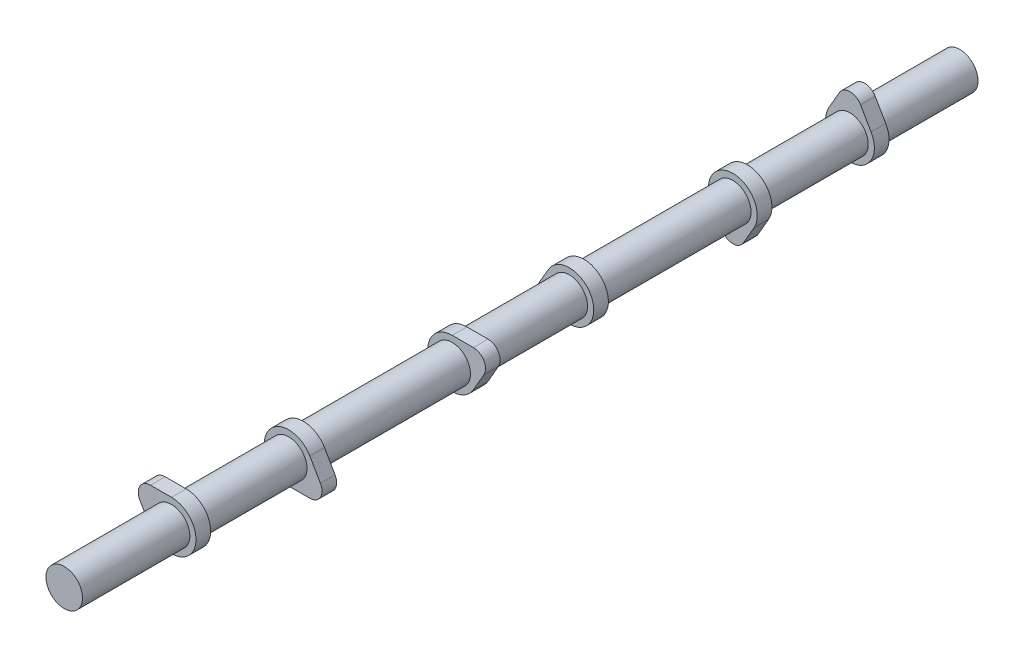
from build123d import *

# Parameters (mm, degrees)
BOSS_EXTRU_1_DEPTH           = 3.81
CORPS_D_PLACER_COPIER2_ANGLE = 180
BOSS_EXTRU_2_START           = -25.4
ESQUISSE4_R                  = 9.5
BOSS_EXTRU_2_DEPTH           = 146.05
R_P_TITION_LIN_AIRE2_COUNT   = 3
R_P_TITION_LIN_AIRE2_PITCH   = 146.05
CORPS_D_PLACER_COPIER3_ANGLE = 120
CORPS_D_PLACER_COPIER4_ANGLE = 120
BOSS_EXTRU_3_START           = 27.94
ESQUISSE5_R                  = 9.5
BOSS_EXTRU_3_DEPTH           = 27.94


with BuildPart() as part:
    # Esquisse1 → Boss.-Extru.1 (new, symmetric)
    with BuildSketch(Plane.XY):
        with BuildLine():
            Line((-5.499261314, 15.875), (-10.998522628, 6.35))
            ThreePointArc((-10.998522628, 6.35), (0, -12.7), (10.998522628, 6.35))
            Line((10.998522628, 6.35), (5.499261314, 15.875))
            ThreePointArc((5.499261314, 15.875), (0, 19.05), (-5.499261314, 15.875))
        make_face()
    extrude(amount=BOSS_EXTRU_1_DEPTH, both=True)


with BuildPart() as body_2:
    # Corps-Déplacer/Copier1: copy of part
    add(part.part.moved(Location((0, 0, 60.96))))


with BuildPart() as body_2_1:
    # Corps-Déplacer/Copier2: moved
    add(body_2.part.rotate(Axis((0, 0, 0), (0, 0, 1)), CORPS_D_PLACER_COPIER2_ANGLE))


with BuildPart() as part_1:
    add(part.part)

    add(body_2_1.part)  # Boss.-Extru.2 merges body 2
    # Esquisse4 → Boss.-Extru.2 (add)
    with BuildSketch(Plane.XY.offset(BOSS_EXTRU_2_START)):
        Circle(ESQUISSE4_R)
    extrude(amount=BOSS_EXTRU_2_DEPTH)


with BuildPart() as r_p_tition_lin_aire2_1:
    # Répétition linéaire2: pattern copy
    add(part_1.part.moved(Location(Vector(0, 0, 1) * (1 * R_P_TITION_LIN_AIRE2_PITCH))))


with BuildPart() as r_p_tition_lin_aire2_2:
    # Répétition linéaire2: pattern copy
    add(part_1.part.moved(Location(Vector(0, 0, 1) * (2 * R_P_TITION_LIN_AIRE2_PITCH))))


with BuildPart() as r_p_tition_lin_aire2_1_1:
    # Corps-Déplacer/Copier3: moved
    add(r_p_tition_lin_aire2_1.part.rotate(Axis((0, 0, 0), (0, 0, 1)), CORPS_D_PLACER_COPIER3_ANGLE))


with BuildPart() as r_p_tition_lin_aire2_2_1:
    # Corps-Déplacer/Copier4: moved
    add(r_p_tition_lin_aire2_2.part.rotate(Axis((0, 0, 0), (0, 0, -1)), CORPS_D_PLACER_COPIER4_ANGLE))


with BuildPart() as part_2:
    add(part_1.part)

    # Esquisse5 → Boss.-Extru.3 (add)
    with BuildSketch(Plane(origin=(0, 0, -25.4), x_dir=(-1, 0, 0), z_dir=(0, 0, -1)).offset(BOSS_EXTRU_3_START)):
        Circle(ESQUISSE5_R)
    extrude(amount=-BOSS_EXTRU_3_DEPTH)


with BuildPart() as r_p_tition_lin_aire2_2_2:
    add(r_p_tition_lin_aire2_2_1.part)

    # Combiner1: union Répétition linéaire2_1, part
    add(r_p_tition_lin_aire2_1_1.part)
    add(part_2.part)


solid = r_p_tition_lin_aire2_2_2.part
